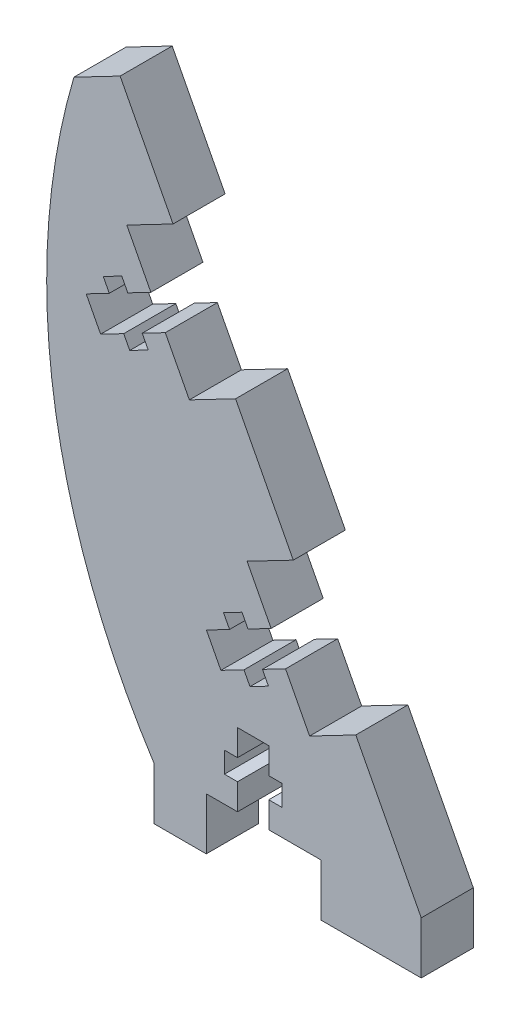
from build123d import *

# Parameters (mm, degrees)
BOSS_EXTRUDE1_DEPTH = 5
SKETCH2_OUTSIDE_W   = 44.609
SKETCH2_OUTSIDE_H   = 67.511
CUT_EXTRUDE1_DEPTH  = 5
SKETCH3_W           = 5
SKETCH3_H           = 5
BOSS_EXTRUDE2_DEPTH = 5


with BuildPart() as part:
    # Sketch1 → Boss-Extrude1 (new body)
    with BuildSketch(Plane.XY):
        with BuildLine():
            Line((-20, 0), (0, 0))
            Line((0, 0), (-27.704916794, 53.220649991))
            ThreePointArc((-27.704916794, 53.220649991), (-29.652591379, 25.770621947), (-20, 0))
        make_face()
    extrude(amount=BOSS_EXTRUDE1_DEPTH)

    # Sketch2 outside → Cut-Extrude1 (cut)
    with BuildSketch(Plane.XY.offset(5)):
        with Locations((-15.1595, 26.6105)):
            Rectangle(SKETCH2_OUTSIDE_W, SKETCH2_OUTSIDE_H)
        with BuildLine():
            Line((-12, 4.5), (-12, 7))
            Line((-12, 7), (-9, 7))
            Line((-9, 7), (-9, 4.5))
            Line((-9, 4.5), (-7.75, 4.5))
            Line((-7.75, 4.5), (-7.75, 2.5))
            Line((-7.75, 2.5), (-9, 2.5))
            Line((-9, 2.5), (-9, 0))
            Line((-9, 0), (0, 0))
            Line((0, 0), (-7.387977812, 14.192173331))
            Line((-7.387977812, 14.192173331), (-9.605504895, 13.037801798))
            Line((-9.605504895, 13.037801798), (-9.028319128, 11.929038256))
            Line((-9.028319128, 11.929038256), (-10.802340795, 11.00554103))
            Line((-10.802340795, 11.00554103), (-11.379526561, 12.114304571))
            Line((-11.379526561, 12.114304571), (-13.597053644, 10.959933038))
            Line((-13.597053644, 10.959933038), (-14.982299484, 13.620965538))
            Line((-14.982299484, 13.620965538), (-12.764772401, 14.775337071))
            Line((-12.764772401, 14.775337071), (-13.341958167, 15.884100612))
            Line((-13.341958167, 15.884100612), (-11.567936501, 16.807597839))
            Line((-11.567936501, 16.807597839), (-10.990750734, 15.698834297))
            Line((-10.990750734, 15.698834297), (-8.773223651, 16.85320583))
            Line((-8.773223651, 16.85320583), (-18.931693143, 36.36744416))
            Line((-18.931693143, 36.36744416), (-21.149220226, 35.213072627))
            Line((-21.149220226, 35.213072627), (-20.572034459, 34.104309086))
            Line((-20.572034459, 34.104309086), (-22.346056125, 33.180811859))
            Line((-22.346056125, 33.180811859), (-22.923241892, 34.289575401))
            Line((-22.923241892, 34.289575401), (-25.140768975, 33.135203868))
            Line((-25.140768975, 33.135203868), (-26.526014815, 35.796236367))
            Line((-26.526014815, 35.796236367), (-24.308487732, 36.9506079))
            Line((-24.308487732, 36.9506079), (-24.885673498, 38.059371442))
            Line((-24.885673498, 38.059371442), (-23.111651832, 38.982868668))
            Line((-23.111651832, 38.982868668), (-22.534466065, 37.874105127))
            Line((-22.534466065, 37.874105127), (-20.316938982, 39.02847666))
            Line((-20.316938982, 39.02847666), (-27.704916794, 53.220649991))
            ThreePointArc((-27.704916794, 53.220649991), (-29.652591379, 25.770621947), (-20, 0))
            Line((-20, 0), (-12, 0))
            Line((-12, 0), (-12, 2.5))
            Line((-12, 2.5), (-13.25, 2.5))
            Line((-13.25, 2.5), (-13.25, 4.5))
            Line((-13.25, 4.5), (-12, 4.5))
        make_face(mode=Mode.SUBTRACT)
    extrude(amount=-CUT_EXTRUDE1_DEPTH, mode=Mode.SUBTRACT)

    # Sketch3 → Boss-Extrude2 (add)
    with BuildSketch(Plane.XY.offset(5)):
        Polygon((-23.269862628, 55.529393057), (-27.704916794, 53.220649991), (-22.625682049, 43.463530826), (-18.190627883, 45.772273892), align=None)
        Polygon((-12.187895911, 34.241133061), (-16.622950076, 31.932389994), (-11.081966718, 21.288259996), (-6.646912552, 23.597003062), align=None)
        Polygon((-5.079234746, 9.757119165), (0, 0), (-4, 0), (-4, -5), (5.636909734, -5), (5.636909734, 0), (-0.64418058, 12.065862231), align=None)
        with Locations((-17.5, -2.5)):
            Rectangle(SKETCH3_W, SKETCH3_H)
    extrude(amount=-BOSS_EXTRUDE2_DEPTH)


solid = part.part
